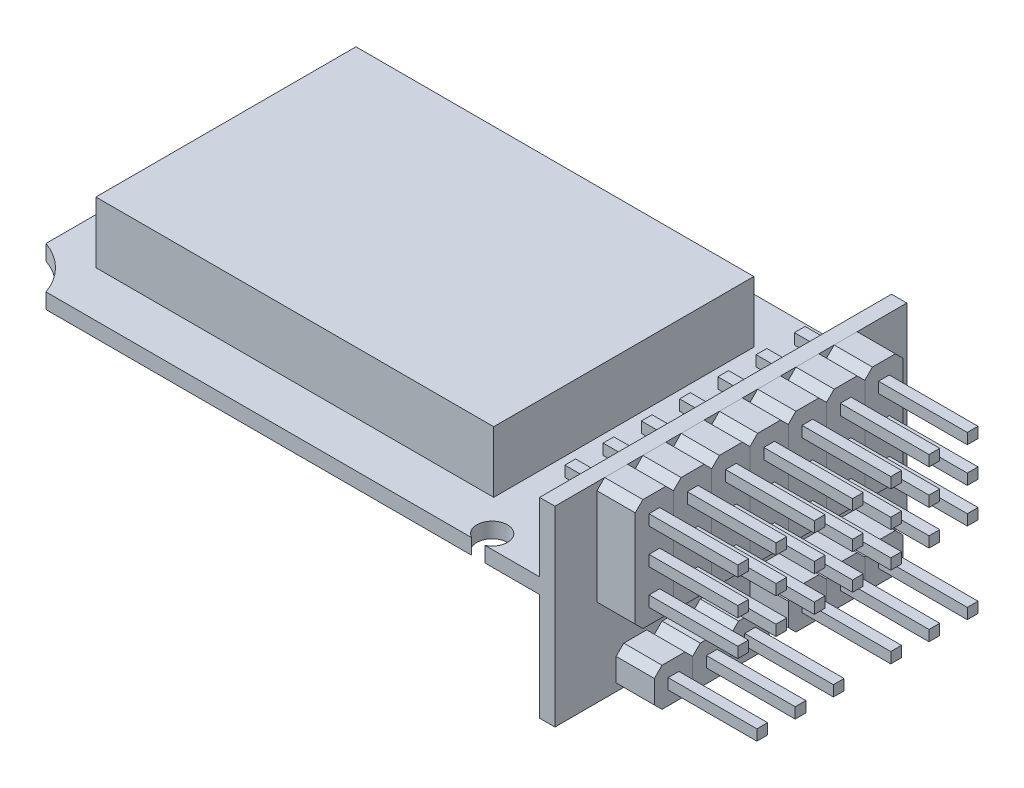
from build123d import *

# Parameters (mm, degrees)
SKETCH1_W                  = 26
SKETCH1_H                  = 17
BOSS_EXTRUDE2_DEPTH        = 1
SKETCH1_4_W                = 26
SKETCH1_4_H                = 17
BOSS_EXTRUDE3_DEPTH        = 5
BOSS_EXTRUDE4_DEPTH        = 2.2
SKETCH1_6_W                = 3.25
SKETCH1_6_H                = 4
BOSS_EXTRUDE5_DEPTH        = 2
BOSS_EXTRUDE5_2_DEPTH      = 2
SKETCH1_7_W                = 7
SKETCH1_7_H                = 7
BOSS_EXTRUDE6_DEPTH        = 1.5
BOSS_EXTRUDE7_DEPTH        = 5.5
BOSS_EXTRUDE7_DEPTH_BACK   = 7
SKETCH1_8_W                = 1
SKETCH1_8_H                = 23
SKETCH3_W                  = 2.5
SKETCH3_H                  = 7.3
SKETCH3_W_2                = 0.7
SKETCH3_H_2                = 0.7
BOSS_EXTRUDE8_DEPTH        = 2.5
SKETCH3_H_3                = 2.5
BOSS_EXTRUDE8_2_DEPTH      = 2.5
BOSS_EXTRUDE8_3_DEPTH      = 2.5
BOSS_EXTRUDE9_DEPTH        = 8.3
BOSS_EXTRUDE9_DEPTH_BACK   = 3
SKETCH3_3_W                = 0.7
SKETCH3_3_H                = 0.7
BOSS_EXTRUDE9_2_DEPTH      = 8.3
BOSS_EXTRUDE9_2_DEPTH_BACK = 3
BOSS_EXTRUDE9_3_DEPTH      = 8.3
BOSS_EXTRUDE9_3_DEPTH_BACK = 3
BOSS_EXTRUDE9_4_DEPTH      = 8.3
BOSS_EXTRUDE9_4_DEPTH_BACK = 3
BOSS_EXTRUDE9_5_DEPTH      = 8.3
BOSS_EXTRUDE9_5_DEPTH_BACK = 3
CHAMFER1_SIZE              = 0.5
LPATTERN1_COUNT            = 7
LPATTERN1_PITCH            = 2.5
CHAMFER2_SIZE              = 0.5
CHAMFER3_SIZE              = 0.5
LPATTERN2_COUNT            = 3
LPATTERN2_PITCH            = 2.5
LPATTERN3_COUNT            = 3
LPATTERN3_PITCH            = 2.5
LPATTERN4_COUNT            = 7
LPATTERN4_PITCH            = 2.5


with BuildPart() as part:
    # Sketch1 → Boss-Extrude2 (new body)
    with BuildSketch(Plane(origin=(0, 0, 0), x_dir=(1, 0, 0), z_dir=(0, 1, 0))):
        with BuildLine():
            Line((31.435889894, 0), (35, 0))
            Line((35, 0), (35, 23))
            Line((35, 23), (2.742640687, 23))
            ThreePointArc((2.742640687, 23), (1.681980515, 21.318019485), (0, 20.257359313))
            Line((0, 20.257359313), (0, 15.435889894))
            ThreePointArc((0, 15.435889894), (1.9, 15), (0, 14.564110106))
            Line((0, 14.564110106), (0, 2.742640687))
            ThreePointArc((0, 2.742640687), (1.681980515, 1.681980515), (2.742640687, 0))
            Line((2.742640687, 0), (30.564110106, 0))
            ThreePointArc((30.564110106, 0), (31, 1.9), (31.435889894, 0))
        make_face()
        with Locations((16, 11.5)):
            Rectangle(SKETCH1_W, SKETCH1_H, mode=Mode.SUBTRACT)
    extrude(amount=BOSS_EXTRUDE2_DEPTH)

    # Sketch1_8 → Boss-Extrude7 (add, two sides: drawn at the far end of the back side and taken through both)
    with BuildSketch(Plane(origin=(0, 0, 0), x_dir=(1, 0, 0), z_dir=(0, 1, 0)).offset(-BOSS_EXTRUDE7_DEPTH_BACK)):
        with Locations((35.5, 11.5)):
            Rectangle(SKETCH1_8_W, SKETCH1_8_H)
    extrude(amount=BOSS_EXTRUDE7_DEPTH + BOSS_EXTRUDE7_DEPTH_BACK)


with BuildPart() as body_2:
    # Sketch1_4 → Boss-Extrude3 (new body)
    with BuildSketch(Plane(origin=(0, 0, 0), x_dir=(1, 0, 0), z_dir=(0, 1, 0))):
        with Locations((16, 11.5)):
            Rectangle(SKETCH1_4_W, SKETCH1_4_H)
    extrude(amount=BOSS_EXTRUDE3_DEPTH)


with BuildPart() as body_3:
    # Sketch1_5 → Boss-Extrude4 (new body)
    with BuildSketch(Plane(origin=(0, 0, 0), x_dir=(1, 0, 0), z_dir=(0, 1, 0))):
        with BuildLine():
            Line((28.5, 20.7), (28.5, 19.7))
            ThreePointArc((28.5, 19.7), (30, 18.2), (31.5, 19.7))
            Line((31.5, 19.7), (31.5, 20.7))
            ThreePointArc((31.5, 20.7), (30, 22.2), (28.5, 20.7))
        make_face()
    extrude(amount=-BOSS_EXTRUDE4_DEPTH)


with BuildPart() as body_4:
    # Sketch1_6 → Boss-Extrude5 (new body)
    with BuildSketch(Plane(origin=(0, 0, 0), x_dir=(1, 0, 0), z_dir=(0, 1, 0))):
        with Locations((20.625, 20)):
            Rectangle(SKETCH1_6_W, SKETCH1_6_H)
    extrude(amount=-BOSS_EXTRUDE5_DEPTH)


with BuildPart() as body_5:
    # Sketch1_6 → Boss-Extrude5 2 (new body)
    with BuildSketch(Plane(origin=(0, 0, 0), x_dir=(1, 0, 0), z_dir=(0, 1, 0))):
        with Locations((29.875, 13)):
            Rectangle(SKETCH1_6_W, SKETCH1_6_H)
    extrude(amount=-BOSS_EXTRUDE5_2_DEPTH)


with BuildPart() as body_6:
    # Sketch1_7 → Boss-Extrude6 (new body)
    with BuildSketch(Plane(origin=(0, 0, 0), x_dir=(1, 0, 0), z_dir=(0, 1, 0))):
        with Locations((11.5, 10.5)):
            Rectangle(SKETCH1_7_W, SKETCH1_7_H)
    extrude(amount=-BOSS_EXTRUDE6_DEPTH)


with BuildPart() as body_7:
    # Sketch3 → Boss-Extrude8 (new body)
    with BuildSketch(Plane(origin=(36, 0, 0), x_dir=(0, 0, -1), z_dir=(1, 0, 0))):
        with Locations((4, 1.85)):
            Rectangle(SKETCH3_W, SKETCH3_H)
        with Locations((4, 4.15)):
            Rectangle(SKETCH3_W_2, SKETCH3_H_2, mode=Mode.SUBTRACT)
        with Locations((4, -0.45)):
            Rectangle(SKETCH3_W_2, SKETCH3_H_2, mode=Mode.SUBTRACT)
        with Locations((4, 1.85)):
            Rectangle(SKETCH3_W_2, SKETCH3_H_2, mode=Mode.SUBTRACT)
    extrude(amount=BOSS_EXTRUDE8_DEPTH)

    # Chamfer1
    chamfer1_edges = [body_7.edges().sort_by_distance(p)[0] for p in [
        (37.25, -1.8, -2.75),
        (37.25, -1.8, -5.25),
        (37.25, 5.5, -5.25),
        (37.25, 5.5, -2.75),
    ]]
    chamfer(chamfer1_edges, length=CHAMFER1_SIZE)


with BuildPart() as body_8:
    # Sketch3 → Boss-Extrude8 2 (new body)
    with BuildSketch(Plane(origin=(36, 0, 0), x_dir=(0, 0, -1), z_dir=(1, 0, 0))):
        with Locations((19, -5.75)):
            Rectangle(SKETCH3_W, SKETCH3_H_3)
        with Locations((19, -5.75)):
            Rectangle(SKETCH3_W_2, SKETCH3_H_2, mode=Mode.SUBTRACT)
    extrude(amount=BOSS_EXTRUDE8_2_DEPTH)

    # Chamfer2
    chamfer2_edges = [body_8.edges().sort_by_distance(p)[0] for p in [
        (37.25, -7, -17.75),
        (37.25, -4.5, -17.75),
        (37.25, -7, -20.25),
        (37.25, -4.5, -20.25),
    ]]
    chamfer(chamfer2_edges, length=CHAMFER2_SIZE)


with BuildPart() as body_9:
    # Sketch3 → Boss-Extrude8 3 (new body)
    with BuildSketch(Plane(origin=(36, 0, 0), x_dir=(0, 0, -1), z_dir=(1, 0, 0))):
        with Locations((10.25, -5.75)):
            Rectangle(SKETCH3_W, SKETCH3_H_3)
        with Locations((10.25, -5.75)):
            Rectangle(SKETCH3_W_2, SKETCH3_H_2, mode=Mode.SUBTRACT)
    extrude(amount=BOSS_EXTRUDE8_3_DEPTH)

    # Chamfer3
    chamfer3_edges = [body_9.edges().sort_by_distance(p)[0] for p in [
        (37.25, -7, -9),
        (37.25, -7, -11.5),
        (37.25, -4.5, -11.5),
        (37.25, -4.5, -9),
    ]]
    chamfer(chamfer3_edges, length=CHAMFER3_SIZE)


with BuildPart() as body_10:
    # Sketch3_3 → Boss-Extrude9 (new, two sides: drawn at the far end of the back side and taken through both)
    with BuildSketch(Plane(origin=(36, 0, 0), x_dir=(0, 0, -1), z_dir=(1, 0, 0)).offset(-BOSS_EXTRUDE9_DEPTH_BACK)):
        with Locations((4, 4.15)):
            Rectangle(SKETCH3_3_W, SKETCH3_3_H)
    extrude(amount=BOSS_EXTRUDE9_DEPTH + BOSS_EXTRUDE9_DEPTH_BACK)


with BuildPart() as body_11:
    # Sketch3_3 → Boss-Extrude9 2 (new, two sides: drawn at the far end of the back side and taken through both)
    with BuildSketch(Plane(origin=(36, 0, 0), x_dir=(0, 0, -1), z_dir=(1, 0, 0)).offset(-BOSS_EXTRUDE9_2_DEPTH_BACK)):
        with Locations((4, -0.45)):
            Rectangle(SKETCH3_3_W, SKETCH3_3_H)
    extrude(amount=BOSS_EXTRUDE9_2_DEPTH + BOSS_EXTRUDE9_2_DEPTH_BACK)


with BuildPart() as body_12:
    # Sketch3_3 → Boss-Extrude9 3 (new, two sides: drawn at the far end of the back side and taken through both)
    with BuildSketch(Plane(origin=(36, 0, 0), x_dir=(0, 0, -1), z_dir=(1, 0, 0)).offset(-BOSS_EXTRUDE9_3_DEPTH_BACK)):
        with Locations((4, 1.85)):
            Rectangle(SKETCH3_3_W, SKETCH3_3_H)
    extrude(amount=BOSS_EXTRUDE9_3_DEPTH + BOSS_EXTRUDE9_3_DEPTH_BACK)


with BuildPart() as body_13:
    # Sketch3_3 → Boss-Extrude9 4 (new, two sides: drawn at the far end of the back side and taken through both)
    with BuildSketch(Plane(origin=(36, 0, 0), x_dir=(0, 0, -1), z_dir=(1, 0, 0)).offset(-BOSS_EXTRUDE9_4_DEPTH_BACK)):
        with Locations((19, -5.75)):
            Rectangle(SKETCH3_3_W, SKETCH3_3_H)
    extrude(amount=BOSS_EXTRUDE9_4_DEPTH + BOSS_EXTRUDE9_4_DEPTH_BACK)


with BuildPart() as body_14:
    # Sketch3_3 → Boss-Extrude9 5 (new, two sides: drawn at the far end of the back side and taken through both)
    with BuildSketch(Plane(origin=(36, 0, 0), x_dir=(0, 0, -1), z_dir=(1, 0, 0)).offset(-BOSS_EXTRUDE9_5_DEPTH_BACK)):
        with Locations((10.25, -5.75)):
            Rectangle(SKETCH3_3_W, SKETCH3_3_H)
    extrude(amount=BOSS_EXTRUDE9_5_DEPTH + BOSS_EXTRUDE9_5_DEPTH_BACK)


with BuildPart() as lpattern1_1:
    # LPattern1: pattern copy
    add(body_11.part.moved(Location(Vector(0, 0, -1) * (1 * LPATTERN1_PITCH))))


with BuildPart() as lpattern1_2:
    # LPattern1: pattern copy
    add(body_11.part.moved(Location(Vector(0, 0, -1) * (2 * LPATTERN1_PITCH))))


with BuildPart() as lpattern1_3:
    # LPattern1: pattern copy
    add(body_11.part.moved(Location(Vector(0, 0, -1) * (3 * LPATTERN1_PITCH))))


with BuildPart() as lpattern1_4:
    # LPattern1: pattern copy
    add(body_11.part.moved(Location(Vector(0, 0, -1) * (4 * LPATTERN1_PITCH))))


with BuildPart() as lpattern1_5:
    # LPattern1: pattern copy
    add(body_11.part.moved(Location(Vector(0, 0, -1) * (5 * LPATTERN1_PITCH))))


with BuildPart() as lpattern1_6:
    # LPattern1: pattern copy
    add(body_11.part.moved(Location(Vector(0, 0, -1) * (6 * LPATTERN1_PITCH))))


with BuildPart() as lpattern1_7:
    # LPattern1: pattern copy
    add(body_12.part.moved(Location(Vector(0, 0, -1) * (1 * LPATTERN1_PITCH))))


with BuildPart() as lpattern1_8:
    # LPattern1: pattern copy
    add(body_12.part.moved(Location(Vector(0, 0, -1) * (2 * LPATTERN1_PITCH))))


with BuildPart() as lpattern1_9:
    # LPattern1: pattern copy
    add(body_12.part.moved(Location(Vector(0, 0, -1) * (3 * LPATTERN1_PITCH))))


with BuildPart() as lpattern1_10:
    # LPattern1: pattern copy
    add(body_12.part.moved(Location(Vector(0, 0, -1) * (4 * LPATTERN1_PITCH))))


with BuildPart() as lpattern1_11:
    # LPattern1: pattern copy
    add(body_12.part.moved(Location(Vector(0, 0, -1) * (5 * LPATTERN1_PITCH))))


with BuildPart() as lpattern1_12:
    # LPattern1: pattern copy
    add(body_12.part.moved(Location(Vector(0, 0, -1) * (6 * LPATTERN1_PITCH))))


with BuildPart() as lpattern1_13:
    # LPattern1: pattern copy
    add(body_10.part.moved(Location(Vector(0, 0, -1) * (1 * LPATTERN1_PITCH))))


with BuildPart() as lpattern1_14:
    # LPattern1: pattern copy
    add(body_10.part.moved(Location(Vector(0, 0, -1) * (2 * LPATTERN1_PITCH))))


with BuildPart() as lpattern1_15:
    # LPattern1: pattern copy
    add(body_10.part.moved(Location(Vector(0, 0, -1) * (3 * LPATTERN1_PITCH))))


with BuildPart() as lpattern1_16:
    # LPattern1: pattern copy
    add(body_10.part.moved(Location(Vector(0, 0, -1) * (4 * LPATTERN1_PITCH))))


with BuildPart() as lpattern1_17:
    # LPattern1: pattern copy
    add(body_10.part.moved(Location(Vector(0, 0, -1) * (5 * LPATTERN1_PITCH))))


with BuildPart() as lpattern1_18:
    # LPattern1: pattern copy
    add(body_10.part.moved(Location(Vector(0, 0, -1) * (6 * LPATTERN1_PITCH))))


with BuildPart() as lpattern2_1:
    # LPattern2: pattern copy
    add(body_13.part.moved(Location(Vector(0, 0, 1) * (1 * LPATTERN2_PITCH))))


with BuildPart() as lpattern2_2:
    # LPattern2: pattern copy
    add(body_13.part.moved(Location(Vector(0, 0, 1) * (2 * LPATTERN2_PITCH))))


with BuildPart() as lpattern2_3:
    # LPattern2: pattern copy
    add(body_8.part.moved(Location(Vector(0, 0, 1) * (1 * LPATTERN2_PITCH))))


with BuildPart() as lpattern2_4:
    # LPattern2: pattern copy
    add(body_8.part.moved(Location(Vector(0, 0, 1) * (2 * LPATTERN2_PITCH))))


with BuildPart() as lpattern3_1:
    # LPattern3: pattern copy
    add(body_14.part.moved(Location(Vector(0, 0, 1) * (1 * LPATTERN3_PITCH))))


with BuildPart() as lpattern3_2:
    # LPattern3: pattern copy
    add(body_14.part.moved(Location(Vector(0, 0, 1) * (2 * LPATTERN3_PITCH))))


with BuildPart() as lpattern3_3:
    # LPattern3: pattern copy
    add(body_9.part.moved(Location(Vector(0, 0, 1) * (1 * LPATTERN3_PITCH))))


with BuildPart() as lpattern3_4:
    # LPattern3: pattern copy
    add(body_9.part.moved(Location(Vector(0, 0, 1) * (2 * LPATTERN3_PITCH))))


with BuildPart() as lpattern4_1:
    # LPattern4: pattern copy
    add(body_7.part.moved(Location(Vector(0, 0, -1) * (1 * LPATTERN4_PITCH))))


with BuildPart() as lpattern4_2:
    # LPattern4: pattern copy
    add(body_7.part.moved(Location(Vector(0, 0, -1) * (2 * LPATTERN4_PITCH))))


with BuildPart() as lpattern4_3:
    # LPattern4: pattern copy
    add(body_7.part.moved(Location(Vector(0, 0, -1) * (3 * LPATTERN4_PITCH))))


with BuildPart() as lpattern4_4:
    # LPattern4: pattern copy
    add(body_7.part.moved(Location(Vector(0, 0, -1) * (4 * LPATTERN4_PITCH))))


with BuildPart() as lpattern4_5:
    # LPattern4: pattern copy
    add(body_7.part.moved(Location(Vector(0, 0, -1) * (5 * LPATTERN4_PITCH))))


with BuildPart() as lpattern4_6:
    # LPattern4: pattern copy
    add(body_7.part.moved(Location(Vector(0, 0, -1) * (6 * LPATTERN4_PITCH))))


solid = Compound([part.part, body_2.part, body_3.part, body_4.part, body_5.part, body_6.part, body_7.part, body_8.part, body_9.part, body_10.part, body_11.part, body_12.part, body_13.part, body_14.part, lpattern1_1.part, lpattern1_2.part, lpattern1_3.part, lpattern1_4.part, lpattern1_5.part, lpattern1_6.part, lpattern1_7.part, lpattern1_8.part, lpattern1_9.part, lpattern1_10.part, lpattern1_11.part, lpattern1_12.part, lpattern1_13.part, lpattern1_14.part, lpattern1_15.part, lpattern1_16.part, lpattern1_17.part, lpattern1_18.part, lpattern2_1.part, lpattern2_2.part, lpattern2_3.part, lpattern2_4.part, lpattern3_1.part, lpattern3_2.part, lpattern3_3.part, lpattern3_4.part, lpattern4_1.part, lpattern4_2.part, lpattern4_3.part, lpattern4_4.part, lpattern4_5.part, lpattern4_6.part])
